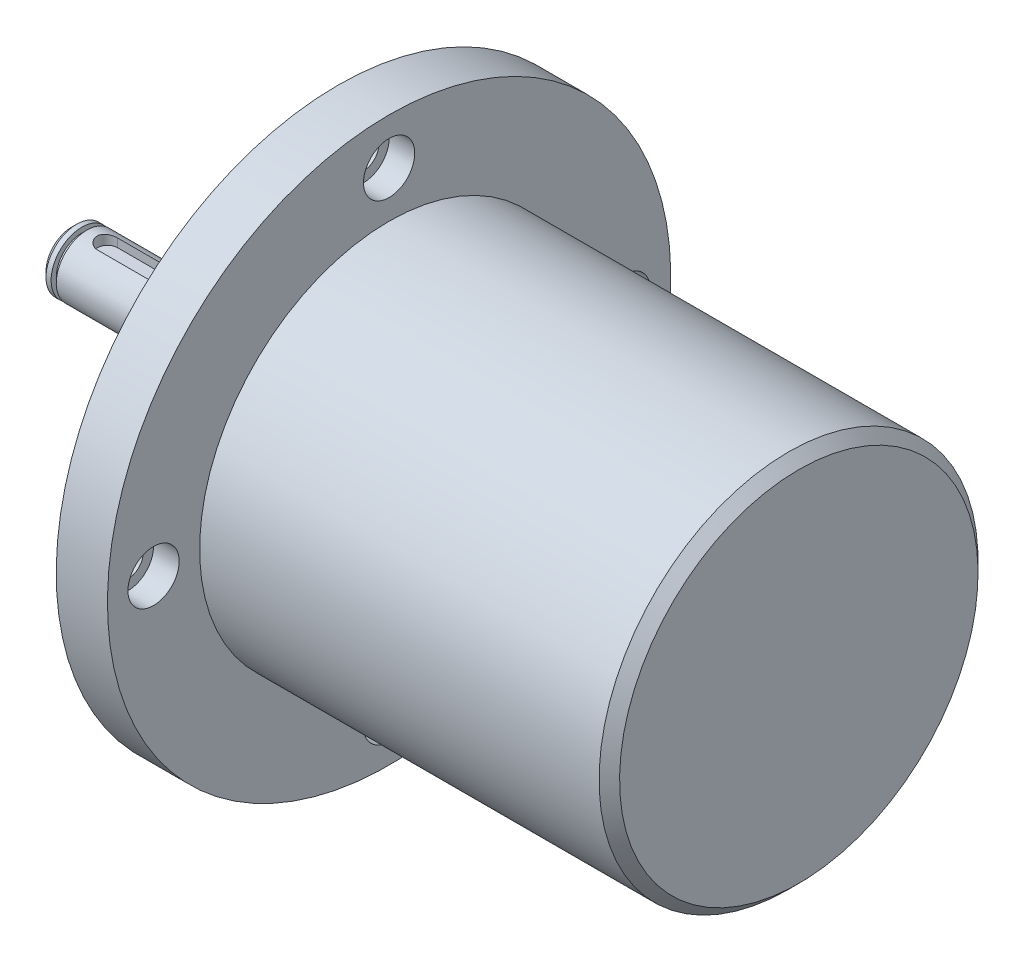
from build123d import *

# Parameters (mm, degrees)
R_P_TITION_CIRCULAIRE1_COUNT = 4
ENL_V_MAT_EXTRU_1_DEPTH      = 10


with BuildPart() as part:
    # Esquisse1 → Révolution1 (revolve)
    with BuildSketch(Plane.XY):
        Polygon((0, 0), (0, 5), (1, 6), (2, 6), (2, 5), (3, 5), (3, 6), (30, 6), (30, 10), (49, 10), (49, 24), (50, 25), (52, 25), (52, 55), (62, 55), (62, 37), (140, 37), (142, 35), (142, 0), align=None)
    revolve(axis=Axis((142, 0, 0), (-1, 0, 0)))

    # Esquisse2 → Enlèvement de matière-Révolution1 (revolve, cut)
    with BuildSketch(Plane.XY, mode=Mode.PRIVATE) as enl_vement_de_mati_re_r_volution1_sk:
        Polygon((44.05702844, 46), (69.730898062, 46), (69.730898062, 51), (57, 51), (57, 49), (44.05702844, 49), align=None)
    enl_vement_de_mati_re_r_volution1 = revolve(enl_vement_de_mati_re_r_volution1_sk.sketch.rotate(Axis((44.05702844, 46, 0), (1, 0, 0)), 90), axis=Axis((44.05702844, 46, 0), (1, 0, 0)), mode=Mode.SUBTRACT)  # turned: the seam where the file's is

    # Répétition circulaire1: Enlèvement de matière-Révolution1 ×4 about axis
    r_p_tition_circulaire1_axis = Axis((0, 0, 0), (1, 0, 0))
    for i in range(1, R_P_TITION_CIRCULAIRE1_COUNT):
        add(enl_vement_de_mati_re_r_volution1.rotate(r_p_tition_circulaire1_axis, i * 360 / R_P_TITION_CIRCULAIRE1_COUNT), mode=Mode.SUBTRACT)

    # Esquisse3 → Enlèv. mat.-Extru.1 (cut)
    with BuildSketch(Plane(origin=(0, 4, 0), x_dir=(1, 0, 0), z_dir=(0, 1, 0))):
        with BuildLine():
            Line((7, 2), (19, 2))
            ThreePointArc((19, 2), (21, 0), (19, -2))
            Line((19, -2), (7, -2))
            ThreePointArc((7, -2), (5, 0), (7, 2))
        make_face()
    extrude(amount=ENL_V_MAT_EXTRU_1_DEPTH, mode=Mode.SUBTRACT)


solid = part.part
